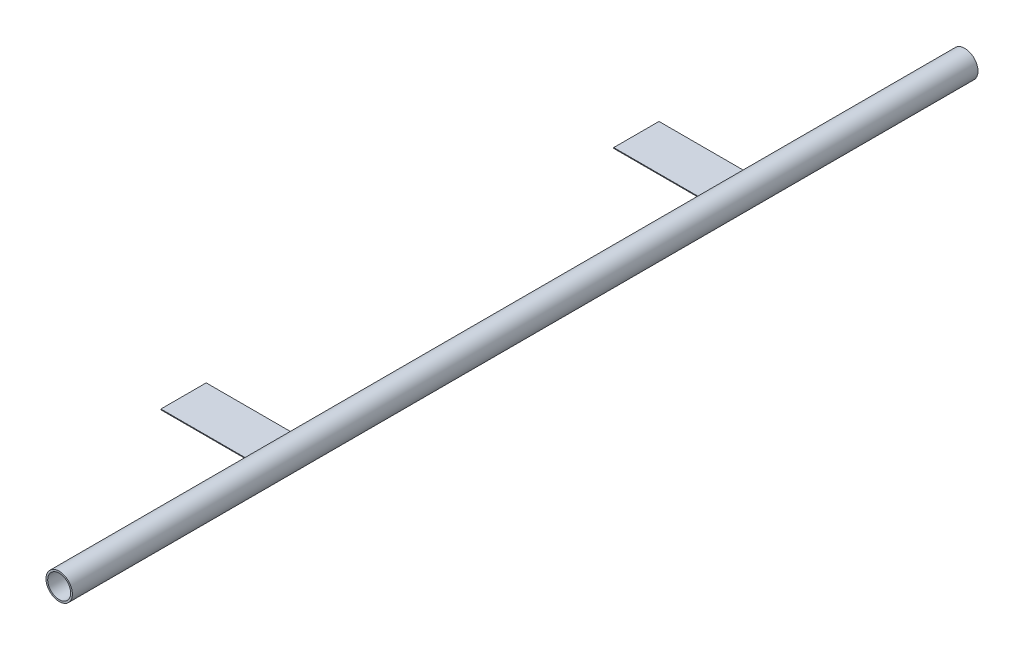
from build123d import *

# Parameters (mm, degrees)
SKETCH1_R           = 44.45
SKETCH1_R_2         = 38.6334
BOSS_EXTRUDE1_DEPTH = 3048
SKETCH2_R           = 12.7
CUT_EXTRUDE1_DEPTH  = 45.45
SKETCH3_W           = 304.8
SKETCH3_H           = 152.4
BOSS_EXTRUDE2_DEPTH = 2.54


with BuildPart() as part:
    # Sketch1 → Boss-Extrude1 (new body)
    with BuildSketch(Plane.XY):
        Circle(SKETCH1_R)
        Circle(SKETCH1_R_2, mode=Mode.SUBTRACT)
    extrude(amount=BOSS_EXTRUDE1_DEPTH)

    # Sketch2 → Cut-Extrude1 (cut, through all)
    with BuildSketch(Plane(origin=(0, 0, 0), x_dir=(0, 0, -1), z_dir=(1, 0, 0))):
        with Locations((-1828.8, 0)):
            Circle(SKETCH2_R)
    extrude(amount=-CUT_EXTRUDE1_DEPTH, mode=Mode.SUBTRACT)

    # Sketch3 → Boss-Extrude2 (add)
    with BuildSketch(Plane(origin=(0, 0, 0), x_dir=(1, 0, 0), z_dir=(0, 1, 0))):
        with Locations((-191.0334, -762)):
            Rectangle(SKETCH3_W, SKETCH3_H)
        with Locations((-191.0334, -2286)):
            Rectangle(SKETCH3_W, SKETCH3_H)
    extrude(amount=BOSS_EXTRUDE2_DEPTH)


solid = part.part
